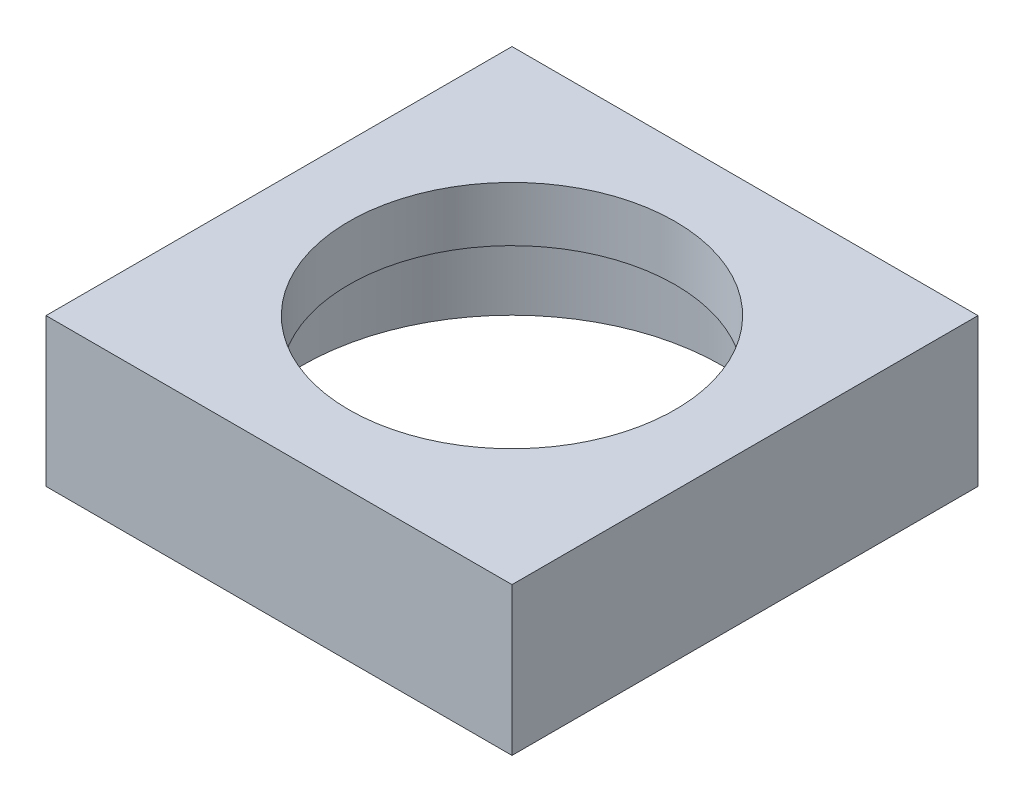
from build123d import *

# Parameters (mm, degrees)
SKETCH1_W           = 10
SKETCH1_H           = 10
SKETCH1_R           = 4.5
BOSS_EXTRUDE1_DEPTH = 3.175
SKETCH2_W           = 10
SKETCH2_H           = 10
SKETCH2_R           = 3.5
BOSS_EXTRUDE2_DEPTH = 1.175


with BuildPart() as part:
    # Sketch1 → Boss-Extrude1 (new body)
    with BuildSketch(Plane(origin=(0, 0, 0), x_dir=(1, 0, 0), z_dir=(0, 1, 0))):
        with Locations((5, -5)):
            Rectangle(SKETCH1_W, SKETCH1_H)
        with Locations((5, -5)):
            Circle(SKETCH1_R, mode=Mode.SUBTRACT)
    extrude(amount=BOSS_EXTRUDE1_DEPTH)

    # Sketch2 → Boss-Extrude2 (add)
    with BuildSketch(Plane(origin=(0, 3.175, 0), x_dir=(1, 0, 0), z_dir=(0, 1, 0))):
        with Locations((5, -5)):
            Rectangle(SKETCH2_W, SKETCH2_H)
        with Locations((5, -5)):
            Circle(SKETCH2_R, mode=Mode.SUBTRACT)
    extrude(amount=-BOSS_EXTRUDE2_DEPTH)


solid = part.part
